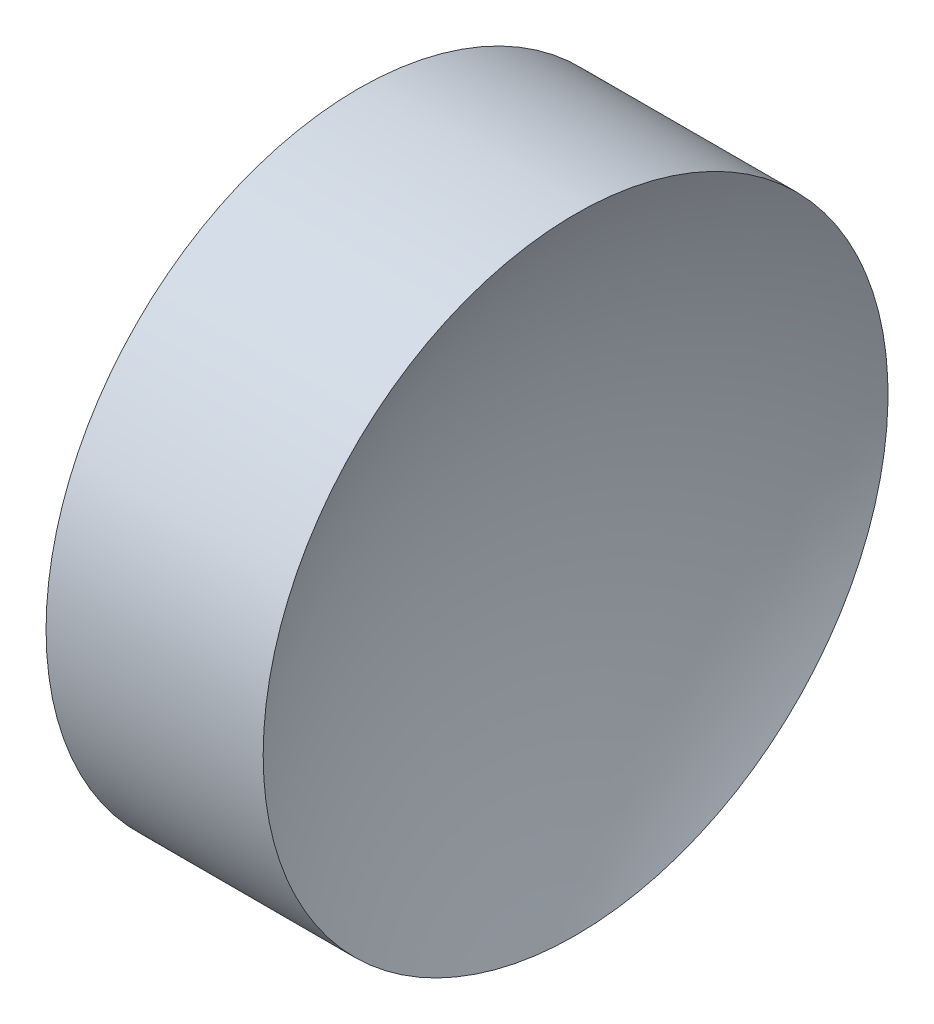
from build123d import *


with BuildPart() as part:
    # 草图1 → 旋转1 (revolve)
    with BuildSketch(Plane.XY, mode=Mode.PRIVATE) as revolve_1_sk:
        with BuildLine():
            Line((47.291563991, 26.089041149), (48.791563991, 26.089041149))
            ThreePointArc((48.791563991, 26.089041149), (49.306928182, 30.215785873), (50.821363992, 34.089041149))
            Line((50.821363992, 34.089041149), (48.041563991, 34.089041149))
            Line((48.041563991, 34.089041149), (45.26176399, 34.089041149))
            ThreePointArc((45.26176399, 34.089041149), (46.7761998, 30.215785873), (47.291563991, 26.089041149))
        make_face()
    revolve(revolve_1_sk.sketch.rotate(Axis((42.449861114, 26.089041149, 0), (1, 0, 0)), 90), axis=Axis((42.449861114, 26.089041149, 0), (1, 0, 0)))  # turned: the seam where the file's is


solid = part.part
